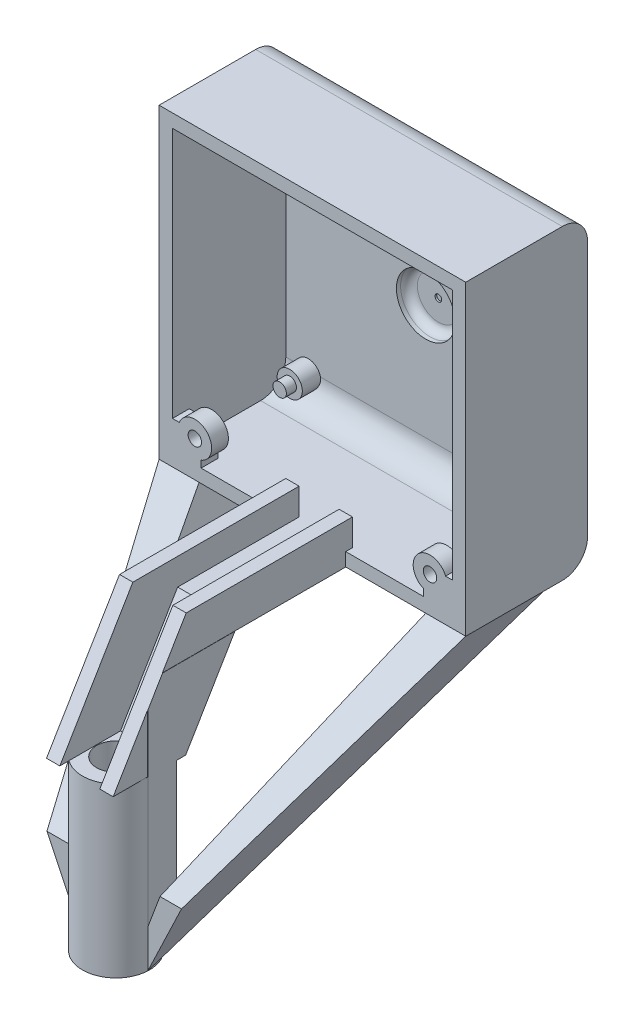
from build123d import *
from build123d.topology import SkipClean

# Parameters (mm, degrees)
SKETCH1_W            = 36.5125
SKETCH1_H            = 36.5125
EXTRUDE1_DEPTH       = 1
SKETCH2_W            = 36.5125
SKETCH2_H            = 36.5125
SKETCH2_W_2          = 33.3375
SKETCH2_H_2          = 33.3375
EXTRUDE2_DEPTH       = 13.5
FILLET7_R            = 3
SKETCH5_R            = 1.5
EXTRUDE5_DEPTH       = 2.2
SKETCH6_R            = 0.8
EXTRUDE6_DEPTH       = 1.2
SKETCH7_R            = 4.5
EXTRUDE7_DEPTH       = 2.5
SKETCH8_R            = 3.5
EXTRUDE9_DEPTH       = 1.5
FILLET8_R            = 1
FILLET10_R           = 1
SKETCH9_R            = 0.4
EXTRUDE10_DEPTH      = 0.2
SKETCH10_R           = 0.8
EXTRUDE11_DEPTH      = 2
EXTRUDE12_DEPTH      = 19
EXTRUDE12_DEPTH_BACK = 0.8
EXTRUDE13_DEPTH      = 55.30808767
EXTRUDE14_DEPTH      = 17
EXTRUDE15_DEPTH      = 70.200859363
SKETCH16_R           = 4
SKETCH16_R_2         = 2.3
EXTRUDE16_DEPTH      = 20
SKETCH17_W           = 7.9375
SKETCH17_H           = 1.5875
EXTRUDE17_DEPTH      = 13.5
EXTRUDE18_START      = -1.5875
EXTRUDE18_DEPTH      = 15.875
EXTRUDE20_REACH      = 87.467
EXTRUDE21_DEPTH      = 1.5875
EXTRUDE22_REACH      = 88.701
EXTRUDE23_START      = -1.5875
EXTRUDE23_DEPTH      = 15.875
EXTRUDE24_REACH      = 87.467
EXTRUDE25_REACH      = 88.701
SKETCH25_W           = 14.2875
SKETCH25_H           = 28.3625
EXTRUDE26_DEPTH      = 1.5875
EXTRUDE27_DEPTH      = 1.613234818


with BuildPart() as part:
    # Sketch1 → Extrude1 (new body)
    with BuildSketch(Plane.XY):
        with Locations((18.25625, -18.25625)):
            Rectangle(SKETCH1_W, SKETCH1_H)
    extrude(amount=EXTRUDE1_DEPTH)

    # Sketch2 → Extrude2 (add)
    with BuildSketch(Plane.XY.offset(1)):
        with Locations((18.25625, -18.25625)):
            Rectangle(SKETCH2_W, SKETCH2_H)
        with Locations((18.25625, -18.25625)):
            Rectangle(SKETCH2_W_2, SKETCH2_H_2, mode=Mode.SUBTRACT)
    extrude(amount=EXTRUDE2_DEPTH)

    # Fillet7
    fillet7_edges = [part.edges().sort_by_distance(p)[0] for p in [
        (18.25625, -1.5875, 1),
        (18.25625, -34.925, 1),
        (18.25625, -36.5125, 0),
        (18.25625, 0, 0),
    ]]
    fillet(fillet7_edges, radius=FILLET7_R)

    # Sketch5 → Extrude5 (add)
    with BuildSketch(Plane.XY.offset(1)):
        with Locations(Location((4.25625, -4.25625, 0), (0, 0, 192.757983374))):
            Circle(SKETCH5_R)
        with Locations(Location((32.25625, -4.25625, 0), (0, 0, 192.757983374))):
            Circle(SKETCH5_R)
        with Locations(Location((4.25625, -32.25625, 0), (0, 0, 167.242016626))):
            Circle(SKETCH5_R)
        with Locations(Location((32.25625, -32.25625, 0), (0, 0, 167.242016626))):
            Circle(SKETCH5_R)
    extrude(amount=EXTRUDE5_DEPTH)

    # Sketch6 → Extrude6 (add)
    with BuildSketch(Plane.XY.offset(3.2)):
        with Locations((4.25625, -32.25625)):
            Circle(SKETCH6_R)
        with Locations((32.25625, -32.25625)):
            Circle(SKETCH6_R)
        with Locations((4.25625, -4.25625)):
            Circle(SKETCH6_R)
        with Locations((32.25625, -4.25625)):
            Circle(SKETCH6_R)
    extrude(amount=EXTRUDE6_DEPTH)

    # Sketch7 → Extrude7 (add)
    with BuildSketch(Plane.XY.offset(1)):
        with Locations((18.25625, -18.25625)):
            Circle(SKETCH7_R)
    extrude(amount=-EXTRUDE7_DEPTH)

    # Sketch8 → Extrude9 (cut)
    with BuildSketch(Plane.XY.offset(1)):
        with Locations((18.25625, -18.25625)):
            Circle(SKETCH8_R)
    extrude(amount=-EXTRUDE9_DEPTH, mode=Mode.SUBTRACT)

    # Fillet8
    fillet8_edges = [part.edges().sort_by_distance(p)[0] for p in [
        (13.75625, -18.25625, -1.5),
    ]]
    fillet(fillet8_edges, radius=FILLET8_R)

    # Fillet10
    fillet10_edges = [part.edges().sort_by_distance(p)[0] for p in [
        (14.75625, -18.25625, -0.5),
    ]]
    fillet(fillet10_edges, radius=FILLET10_R)

    # Sketch9 → Extrude10 (cut)
    with BuildSketch(Plane.XY.offset(-0.5)):
        with Locations((18.25625, -18.25625)):
            Circle(SKETCH9_R)
    extrude(amount=-EXTRUDE10_DEPTH, mode=Mode.SUBTRACT)

    # Sketch10 → Extrude11 (add)
    with BuildSketch(Plane.XY.offset(14.5)):
        with BuildLine():
            Line((31.5125, -34.11281563), (31.5125, -36.512569909))
            Line((31.5125, -36.512569909), (36.5125, -36.5125))
            Line((36.5125, -36.5125), (36.5125, -31.5125))
            Line((36.5125, -31.5125), (34.11281563, -31.5125))
            ThreePointArc((34.11281563, -31.5125), (30.842036438, -30.842036438), (31.5125, -34.11281563))
        make_face()
        with Locations((32.25625, -32.25625)):
            Circle(SKETCH10_R, mode=Mode.SUBTRACT)
        with BuildLine():
            Line((2.39968437, -31.5125), (0, -31.5125))
            Line((0, -31.5125), (0, -36.5125))
            Line((0, -36.5125), (5, -36.5125))
            Line((5, -36.5125), (5, -34.11281563))
            ThreePointArc((5, -34.11281563), (5.670463562, -30.842036438), (2.39968437, -31.5125))
        make_face()
        with Locations((4.25625, -32.25625)):
            Circle(SKETCH10_R, mode=Mode.SUBTRACT)
    extrude(amount=-EXTRUDE11_DEPTH)

    # Sketch11 → Extrude12 (add, two sides)
    with BuildSketch(Plane.XY.offset(14.5)) as extrude12_sk:
        Polygon((14.2875, -36.5125), (14.2875, -31.75), (15.875, -31.75), (15.875, -33.3375), (15.875, -34.925), (20.6375, -34.925), (20.6375, -33.3375), (20.6375, -31.75), (22.225, -31.75), (22.225, -36.5125), align=None)
    extrude(amount=EXTRUDE12_DEPTH)
    extrude(extrude12_sk.sketch, amount=-EXTRUDE12_DEPTH_BACK)

    # Sketch13 → Extrude13 (cut, through all)
    with BuildSketch(Plane.ZY.offset(-14.2875)):
        Polygon((33.5, -31.75), (25.5, -36.5125), (33.5, -36.5125), align=None)
    extrude(amount=-EXTRUDE13_DEPTH, mode=Mode.SUBTRACT)

    # Sketch14 → Extrude14 (add)
    with BuildSketch(Plane(origin=(0, -38.166778126, 22.721160103), x_dir=(1, 0, 0), z_dir=(0, -0.8592647834640841, 0.5115310664059621))):
        Polygon((22.225, 12.544258888), (22.225, 5.144258888), (14.2875, 5.144258888), (14.2875, 12.544258888), (15.875, 12.544258888), (15.875, 6.33740224), (20.6375, 6.33740224), (20.6375, 12.544258888), align=None)
    extrude(amount=EXTRUDE14_DEPTH)

    # Sketch15 → Extrude15 (cut, through all)
    with BuildSketch(Plane.ZY.offset(-14.2875)):
        Polygon((42.196028129, -46.357501319), (33.58401453, -46.357501319), (35.837468731, -50.14283121), align=None)
    extrude(amount=-EXTRUDE15_DEPTH, mode=Mode.SUBTRACT)

    # Sketch16 → Extrude16 (add)
    with BuildSketch(Plane.XZ.offset(46.357501319)):
        with Locations(Location((18.25625, 37.89002133, 0), (0, 0, 53.465087278))):
            Circle(SKETCH16_R)
        with Locations(Location((18.25625, 37.89002133, 0), (0, 0, 270))):
            Circle(SKETCH16_R_2, mode=Mode.SUBTRACT)
    extrude(amount=EXTRUDE16_DEPTH)

    # Sketch17 → Extrude17 (add)
    with BuildSketch(Plane.XY.offset(14.5)):
        with Locations((18.25625, -35.71875)):
            Rectangle(SKETCH17_W, SKETCH17_H)
    extrude(amount=EXTRUDE17_DEPTH)

    # Sketch18 → Extrude18 (add)
    with SkipClean():  # the faces are left unmerged after this step: merging them gives an invalid solid
        with BuildSketch(Plane.ZY.offset(-14.2875).offset(EXTRUDE18_START)):
            Polygon((38.1, -39.477034121), (38.1, -66.357501319), (3.495412711, -34.925), (35.390117188, -34.925), align=None)
        extrude(amount=EXTRUDE18_DEPTH)

    # Extrude20: up to this face of the body (flat: up to its plane)
    extrude20_end = Plane(part.part.faces().sort_by_distance((7.881670557, -51.329678598, 21.555608644))[0])
    # Sketch19 → Extrude20 (cut, up to the picked face)
    with BuildSketch(Plane.XY.offset(38.1), mode=Mode.PRIVATE) as extrude20_sk1:
        Polygon((0, -66.357501319), (14.261765182, -66.357501319), (0, -36.5125), align=None)
    extrude20_tool1 = split(extrude(extrude20_sk1.sketch, amount=-EXTRUDE20_REACH, mode=Mode.PRIVATE), bisect_by=extrude20_end, keep=Keep.BOTH, mode=Mode.PRIVATE)
    # Sketch19 → Extrude20 (cut, up to the picked face)
    with BuildSketch(Plane.XY.offset(38.1), mode=Mode.PRIVATE) as extrude20_sk2:
        Polygon((4.7625, -36.5125), (14.2875, -36.5125), (14.2875, -61.9125), align=None)
    extrude20_tool2 = split(extrude(extrude20_sk2.sketch, amount=-EXTRUDE20_REACH, mode=Mode.PRIVATE), bisect_by=extrude20_end, keep=Keep.BOTH, mode=Mode.PRIVATE)
    add(extrude20_tool1.solids().sort_by(Axis((4.753922, -56.409168, 38.1), (0, 0, -1)))[0], mode=Mode.SUBTRACT)
    add(extrude20_tool2.solids().sort_by(Axis((11.1125, -44.979167, 38.1), (0, 0, -1)))[0], mode=Mode.SUBTRACT)

    # Sketch20 → Extrude21 (cut)
    with SkipClean():  # the faces are left unmerged after this step: merging them gives an invalid solid
        with BuildSketch(Plane(origin=(15.875, 0, 0), x_dir=(0, 0, -1), z_dir=(1, 0, 0))):
            Polygon((-34.676044286, -63.247408093), (-33.89002133, -62.533437214), (-5.243119066, -36.5125), (-27.723162183, -36.5125), (-33.58401453, -46.357501319), (-33.89002133, -46.357501319), (-34.676044286, -46.357501319), align=None)
        extrude(amount=-EXTRUDE21_DEPTH, mode=Mode.SUBTRACT)

    # Extrude22: up to this plane
    with SkipClean():  # the faces are left unmerged after this step: merging them gives an invalid solid
        extrude22_end = Plane(origin=(4.7625, -36.5125, -19.465058372), z_dir=(-0.9363291775690445, -0.3511234415883917, 0))
        # Sketch21 → Extrude22 (cut, up to the surface)
        with BuildSketch(Plane.ZY, mode=Mode.PRIVATE) as extrude22_sk1:
            Polygon((38.1, -57.949167484), (38.1, -36.5125), (14.5, -36.5125), align=None)
        extrude22_tool1 = split(extrude(extrude22_sk1.sketch, amount=-EXTRUDE22_REACH, mode=Mode.PRIVATE), bisect_by=extrude22_end, keep=Keep.BOTH, mode=Mode.PRIVATE)
        add(extrude22_tool1.solids().sort_by_distance((0, -43.658056, 30.233333))[0], mode=Mode.SUBTRACT)

    # Sketch22 → Extrude23 (add)
    with BuildSketch(Plane(origin=(22.225, 0, 0), x_dir=(0, 0, -1), z_dir=(1, 0, 0)).offset(EXTRUDE23_START)):
        Polygon((-5.243119066, -36.5125), (-38.1, -66.357501319), (-38.1, -39.477034121), (-35.390117188, -34.925), (-4, -34.925), align=None)
    extrude(amount=EXTRUDE23_DEPTH)

    # Extrude24: up to this face of the body (flat: up to its plane)
    extrude24_end = Plane(part.part.faces().sort_by_distance((28.630829443, -51.329678598, 21.555608644))[0])
    # Sketch23 → Extrude24 (cut, up to the picked face)
    with BuildSketch(Plane.XY.offset(38.1), mode=Mode.PRIVATE) as extrude24_sk1:
        Polygon((22.250734818, -66.357501319), (36.5125, -66.357501319), (36.5125, -36.5125), align=None)
    extrude24_tool1 = split(extrude(extrude24_sk1.sketch, amount=-EXTRUDE24_REACH, mode=Mode.PRIVATE), bisect_by=extrude24_end, keep=Keep.BOTH, mode=Mode.PRIVATE)
    # Sketch23 → Extrude24 (cut, up to the picked face)
    with BuildSketch(Plane.XY.offset(38.1), mode=Mode.PRIVATE) as extrude24_sk2:
        Polygon((22.250734818, -61.84387382), (22.250734818, -36.5125), (31.75, -36.5125), align=None)
    extrude24_tool2 = split(extrude(extrude24_sk2.sketch, amount=-EXTRUDE24_REACH, mode=Mode.PRIVATE), bisect_by=extrude24_end, keep=Keep.BOTH, mode=Mode.PRIVATE)
    add(extrude24_tool1.solids().sort_by(Axis((31.758578, -56.409168, 38.1), (0, 0, -1)))[0], mode=Mode.SUBTRACT)
    add(extrude24_tool2.solids().sort_by(Axis((25.417157, -44.956291, 38.1), (0, 0, -1)))[0], mode=Mode.SUBTRACT)

    # Extrude25: up to this plane
    extrude25_end = Plane(origin=(31.75, -36.5125, -19.465058372), z_dir=(0.9363291775690447, -0.3511234415883913, 0))
    # Sketch24 → Extrude25 (cut, up to the surface)
    with BuildSketch(Plane(origin=(36.5125, 0, 0), x_dir=(0, 0, -1), z_dir=(1, 0, 0)), mode=Mode.PRIVATE) as extrude25_sk1:
        Polygon((-14.5, -36.5125), (-36.335175781, -36.5125), (-38.1, -39.477034121), (-38.1, -57.949167484), align=None)
    extrude25_tool1 = split(extrude(extrude25_sk1.sketch, amount=-EXTRUDE25_REACH, mode=Mode.PRIVATE), bisect_by=extrude25_end, keep=Keep.BOTH, mode=Mode.PRIVATE)
    add(extrude25_tool1.solids().sort_by_distance((36.5125, -43.722399, 30.157276))[0], mode=Mode.SUBTRACT)

    # Sketch25 → Extrude26 (cut)
    with BuildSketch(Plane(origin=(0, -34.925, 0), x_dir=(1, 0, 0), z_dir=(0, 1, 0))):
        with Locations((7.14375, -28.68125)):
            Rectangle(SKETCH25_W, SKETCH25_H)
        with Locations((29.36875, -28.68125)):
            Rectangle(SKETCH25_W, SKETCH25_H)
    extrude(amount=-EXTRUDE26_DEPTH, mode=Mode.SUBTRACT)

    # Sketch26 → Extrude27 (cut)
    with BuildSketch(Plane.ZY.offset(-20.6375)):
        Polygon((34.676044286, -46.357501319), (33.58401453, -46.357501319), (27.723162183, -36.5125), (5.243119066, -36.5125), (34.676044286, -63.247408093), align=None)
    extrude(amount=-EXTRUDE27_DEPTH, mode=Mode.SUBTRACT)


solid = part.part
